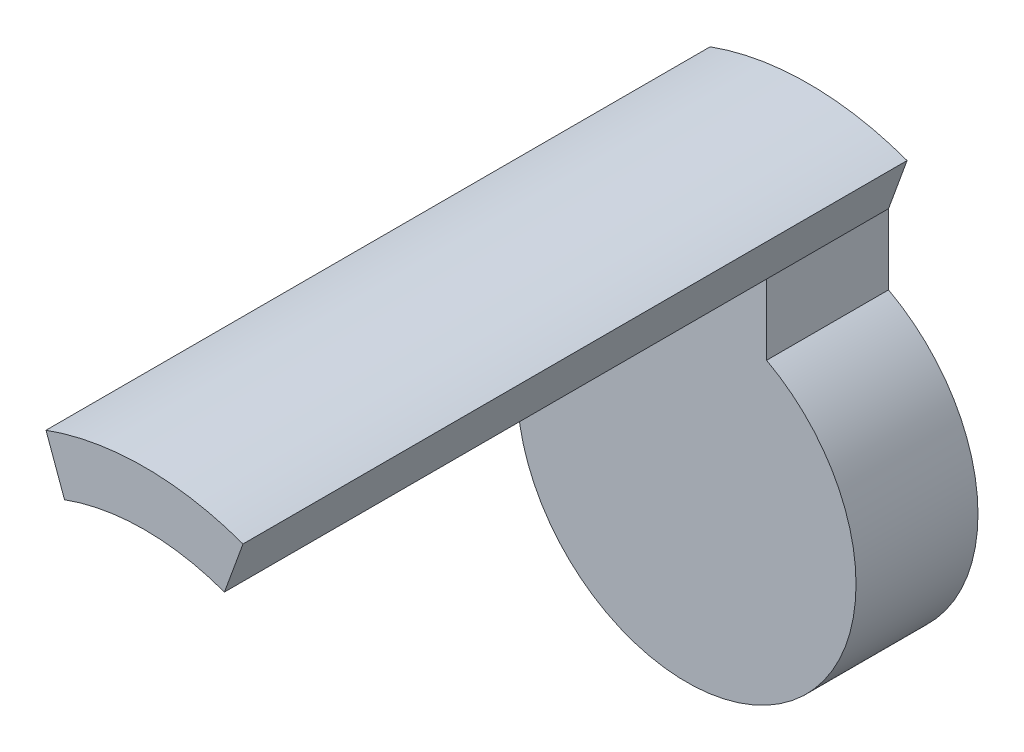
from build123d import *

# Parameters (mm, degrees)
SKETCH_1_R               = 8.5
SKETCH_1_R_2             = 3.6
SKETCH_1_R_3             = 1.25
SKETCH_1_R_4             = 0.6
EXTRUDE_1_DEPTH          = 9
SKETCH_2_R               = 4.3
CUT_EXTRUDE_1_DEPTH      = 0.8
SKETCH_3_R               = 5.9
SKETCH_3_R_2             = 3.6
EXTRUDE_2_DEPTH          = 2.5
SKETCH_5_R               = 4.3
CUT_EXTRUDE_2_DEPTH      = 0.8
EXTRUDE_3_DEPTH          = 7
CUT_EXTRUDE_6_DEPTH      = 1
CUT_EXTRUDE_6_DEPTH_BACK = 17
EXTRUDE_4_DEPTH          = 3.6
SKETCH_8_R               = 3.2
CUT_EXTRUDE_3_DEPTH      = 2


with BuildPart() as part:
    # 스케치1 → 보스-돌출1 (new body)
    with BuildSketch(Plane.XY):
        Circle(SKETCH_1_R)
        Circle(SKETCH_1_R_2, mode=Mode.SUBTRACT)
        with Locations((6.125, 0)):
            Circle(SKETCH_1_R_3, mode=Mode.SUBTRACT)
        with Locations((-6.8, 0)):
            Circle(SKETCH_1_R_4, mode=Mode.SUBTRACT)
    extrude(amount=EXTRUDE_1_DEPTH)

    # 스케치2 → 컷-돌출1 (cut)
    with BuildSketch(Plane.XY.offset(9)):
        Circle(SKETCH_2_R)
    extrude(amount=-CUT_EXTRUDE_1_DEPTH, mode=Mode.SUBTRACT)

    # 스케치3 → 보스-돌출2 (add)
    with BuildSketch(Plane(origin=(0, 0, 0), x_dir=(-1, 0, 0), z_dir=(0, 0, -1))):
        Circle(SKETCH_3_R)
        Circle(SKETCH_3_R_2, mode=Mode.SUBTRACT)
    extrude(amount=EXTRUDE_2_DEPTH)

    # 스케치4 → 컷-회전1 (revolve, cut)
    with BuildSketch(Plane(origin=(0, 0, 0), x_dir=(0, 0, -1), z_dir=(1, 0, 0))):
        Polygon((2.5, 5.9), (0, 5.9), (1.25, 4.6), align=None)
    revolve(axis=Axis((0, 0, 0), (0, 0, -1)), mode=Mode.SUBTRACT)

    # 스케치5 → 컷-돌출2 (cut)
    with BuildSketch(Plane(origin=(0, 0, -2.5), x_dir=(-1, 0, 0), z_dir=(0, 0, -1))):
        Circle(SKETCH_5_R)
    extrude(amount=-CUT_EXTRUDE_2_DEPTH, mode=Mode.SUBTRACT)

    # 스케치6 → 보스-돌출3 (add)
    with BuildSketch(Plane(origin=(0, 0, 0), x_dir=(-1, 0, 0), z_dir=(0, 0, -1))):
        with BuildLine():
            Line((-2.907171218, 7.987387277), (-2.359938989, 6.483879083))
            ThreePointArc((-2.359938989, 6.483879083), (0, 6.9), (2.359938989, 6.483879083))
            Line((2.359938989, 6.483879083), (2.907171218, 7.987387277))
            ThreePointArc((2.907171218, 7.987387277), (0, 8.5), (-2.907171218, 7.987387277))
        make_face()
    extrude(amount=EXTRUDE_3_DEPTH)

    # 스케치10 → 컷-돌출6 (cut, two sides)
    with BuildSketch(Plane(origin=(0, 0, -7), x_dir=(-1, 0, 0), z_dir=(0, 0, -1))) as cut_extrude_6_sk:
        with BuildLine():
            ThreePointArc((-2.907171218, 7.987387277), (0, -8.5), (2.907171218, 7.987387277))
            Line((2.907171218, 7.987387277), (2.359938989, 6.483879083))
            ThreePointArc((2.359938989, 6.483879083), (0, 6.9), (-2.359938989, 6.483879083))
            Line((-2.359938989, 6.483879083), (-2.907171218, 7.987387277))
        make_face()
    extrude(amount=CUT_EXTRUDE_6_DEPTH, mode=Mode.SUBTRACT)
    extrude(cut_extrude_6_sk.sketch, amount=-CUT_EXTRUDE_6_DEPTH_BACK, mode=Mode.SUBTRACT)

    # 스케치7 → 보스-돌출4 (add)
    with BuildSketch(Plane(origin=(0, 0, -7), x_dir=(-1, 0, 0), z_dir=(0, 0, -1))):
        with BuildLine():
            Line((-2.359938989, 6.483879083), (-2.359938989, 4.408025405))
            ThreePointArc((-2.359938989, 4.408025405), (0, -5), (2.359938989, 4.408025405))
            Line((2.359938989, 4.408025405), (2.359938989, 6.483879083))
            Line((2.359938989, 6.483879083), (2.907171218, 7.987387277))
            ThreePointArc((2.907171218, 7.987387277), (0, 8.5), (-2.907171218, 7.987387277))
            Line((-2.907171218, 7.987387277), (-2.359938989, 6.483879083))
        make_face()
    extrude(amount=EXTRUDE_4_DEPTH)

    # 스케치8 → 컷-돌출3 (cut)
    with BuildSketch(Plane(origin=(0, 0, -10.6), x_dir=(-1, 0, 0), z_dir=(0, 0, -1))):
        Circle(SKETCH_8_R)
    extrude(amount=-CUT_EXTRUDE_3_DEPTH, mode=Mode.SUBTRACT)


solid = part.part
